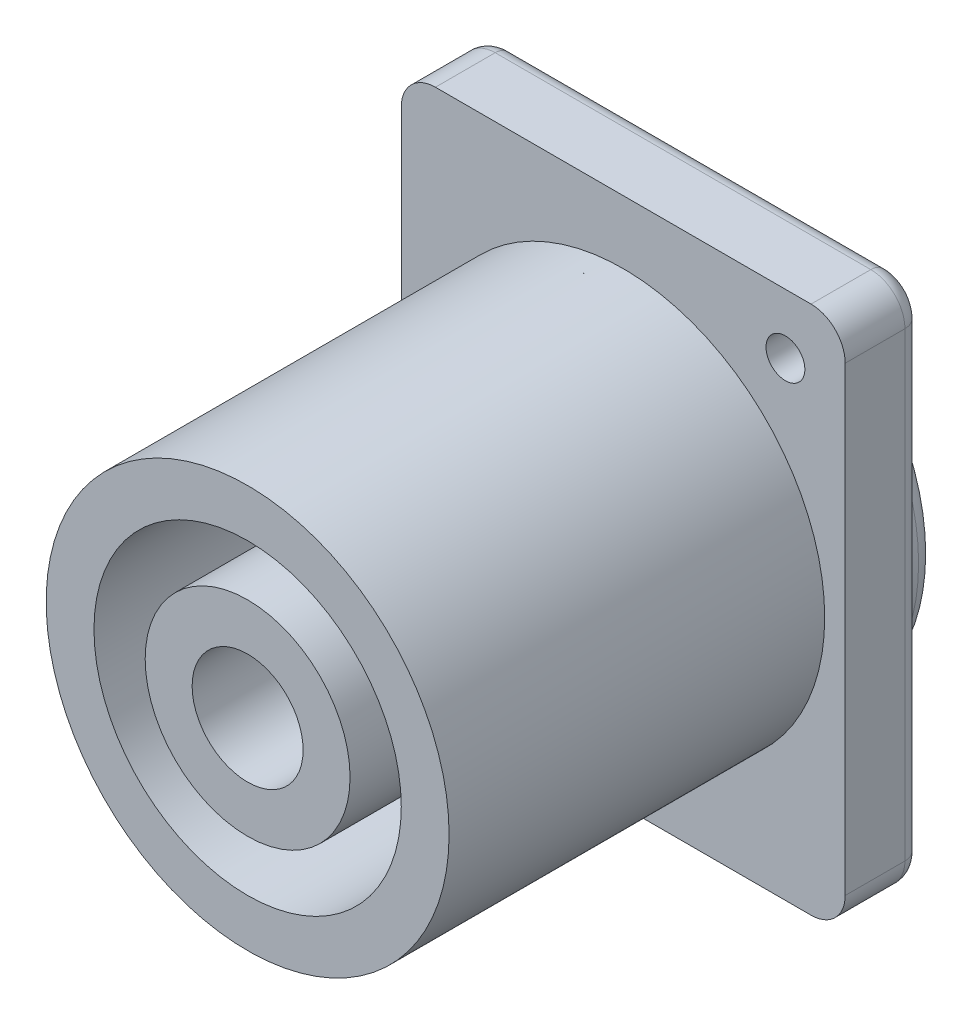
from build123d import *

# Parameters (mm, degrees)
ESQUISSE1_W             = 26
ESQUISSE1_H             = 31
ESQUISSE1_R             = 1.137507792
ESQUISSE1_R_2           = 1.235295656
BOSS_EXTRU_1_DEPTH      = 4.5
CHANFREIN1_SIZE         = 1
CONG_1_R                = 2
CONG_2_R                = 1
ESQUISSE2_R             = 11.8
BOSS_EXTRU_2_DEPTH      = 2
CONG_3_R                = 1
ESQUISSE3_R             = 11.8
BOSS_EXTRU_3_DEPTH      = 22
ESQUISSE4_R             = 9
ESQUISSE4_R_2           = 6
ESQUISSE4_R_3           = 3.25
ENL_V_MAT_EXTRU_1_DEPTH = 30


with BuildPart() as part:
    # Esquisse1 → Boss.-Extru.1 (new body)
    with BuildSketch(Plane.XY):
        with Locations((-6.9364829, -3.762135922)):
            Rectangle(ESQUISSE1_W, ESQUISSE1_H)
        with Locations((2.5635171, 8.237864078)):
            Circle(ESQUISSE1_R, mode=Mode.SUBTRACT)
        with Locations((-16.4364829, -15.762135922)):
            Circle(ESQUISSE1_R_2, mode=Mode.SUBTRACT)
    extrude(amount=BOSS_EXTRU_1_DEPTH)

    # Chanfrein1
    chanfrein1_edges = [part.edges().sort_by_distance(p)[0] for p in [
        (1.426009307, 8.237864078, 0),
        (-17.671778557, -15.762135922, 0),
    ]]
    chamfer(chanfrein1_edges, length=CHANFREIN1_SIZE)

    # Congé1
    cong_1_edges = [part.edges().sort_by_distance(p)[0] for p in [
        (-19.9364829, 11.737864078, 2.25),
        (6.0635171, 11.737864078, 2.25),
        (6.0635171, -19.262135922, 2.25),
        (-19.9364829, -19.262135922, 2.25),
    ]]
    fillet(cong_1_edges, radius=CONG_1_R)

    # Congé2
    cong_2_edges = [part.edges().sort_by_distance(p)[0] for p in [
        (-6.9364829, 11.737864078, 0),
        (-19.9364829, -3.762135922, 0),
        (6.0635171, -3.762135922, 0),
        (-6.9364829, -19.262135922, 0),
        (-19.350696463, 11.15207764, 0),
        (-19.350696463, -18.676349485, 0),
        (5.477730662, -18.676349485, 0),
        (5.477730662, 11.15207764, 0),
    ]]
    fillet(cong_2_edges, radius=CONG_2_R)

    # Esquisse2 → Boss.-Extru.2 (add)
    with BuildSketch(Plane(origin=(0, 0, 0), x_dir=(-1, 0, 0), z_dir=(0, 0, -1))):
        with Locations((6.9364829, -3.762135922)):
            Circle(ESQUISSE2_R)
    extrude(amount=BOSS_EXTRU_2_DEPTH)

    # Congé3
    cong_3_edges = [part.edges().sort_by_distance(p)[0] for p in [
        (4.8635171, -3.762135922, -2),
    ]]
    fillet(cong_3_edges, radius=CONG_3_R)

    # Esquisse3 → Boss.-Extru.3 (add)
    with BuildSketch(Plane.XY.offset(4.5)):
        with Locations((-6.9364829, -3.762135922)):
            Circle(ESQUISSE3_R)
    extrude(amount=BOSS_EXTRU_3_DEPTH)

    # Esquisse4 → Enlèv. mat.-Extru.1 (cut)
    with BuildSketch(Plane(origin=(0, 0, -2), x_dir=(-1, 0, 0), z_dir=(0, 0, -1))):
        with Locations((6.9364829, -3.762135922)):
            Circle(ESQUISSE4_R)
        with Locations((6.9364829, -3.762135922)):
            Circle(ESQUISSE4_R_2, mode=Mode.SUBTRACT)
        with Locations((6.9364829, -3.762135922)):
            Circle(ESQUISSE4_R_3)
    extrude(amount=-ENL_V_MAT_EXTRU_1_DEPTH, mode=Mode.SUBTRACT)


solid = part.part
